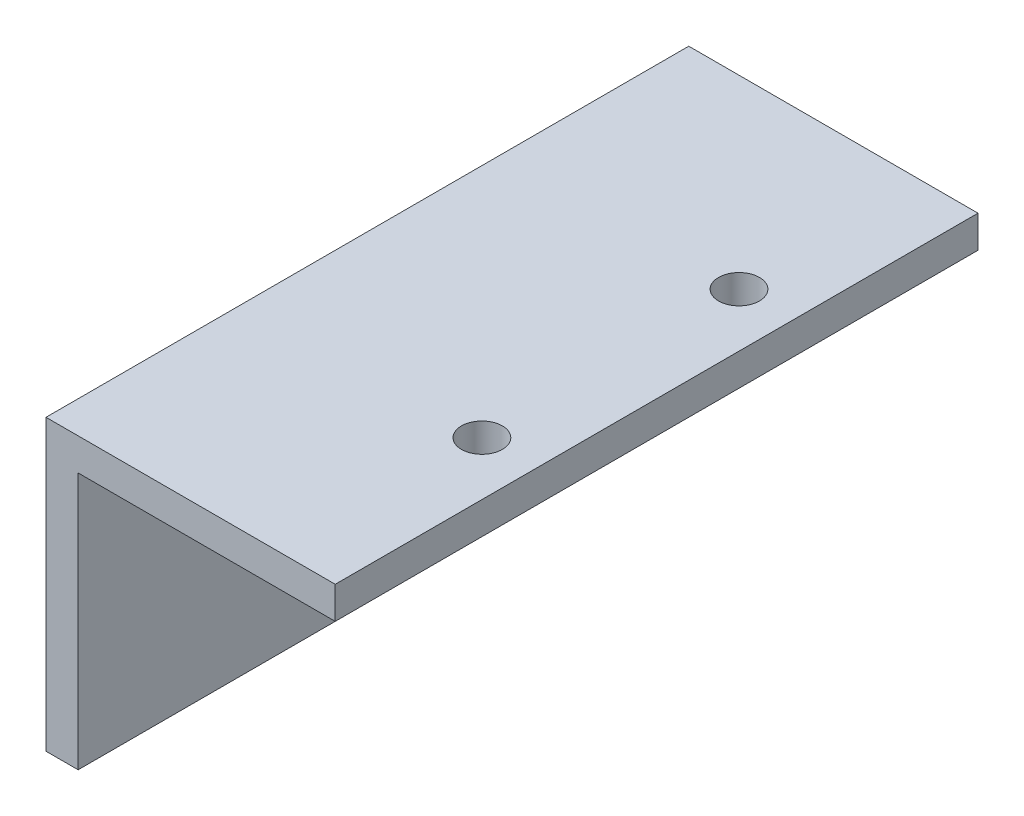
from build123d import *

# Parameters (mm, degrees)
BOSS_EXTRUDE1_DEPTH = 63.5
CUT_EXTRUDE1_REACH  = 30.575
SKETCH2_R           = 2.0193


with BuildPart() as part:
    # Sketch1 → Boss-Extrude1 (new body)
    with BuildSketch(Plane.XY):
        Polygon((0, 0), (0, 28.575), (28.575, 28.575), (28.575, 25.4), (3.175, 25.4), (3.175, 0), align=None)
    extrude(amount=BOSS_EXTRUDE1_DEPTH)

    # Sketch2 → Cut-Extrude1 (cut, up to next)
    with BuildSketch(Plane(origin=(0, 28.575, 0), x_dir=(1, 0, 0), z_dir=(0, 1, 0)), mode=Mode.PRIVATE) as cut_extrude1_sk1:
        with Locations((23.275, -43.710246093)):
            Circle(SKETCH2_R)
    cut_extrude1_tool1 = extrude(cut_extrude1_sk1.sketch, amount=-CUT_EXTRUDE1_REACH, mode=Mode.PRIVATE) & part.part
    add(cut_extrude1_tool1.solids().sort_by_distance((23.275, 28.575, 43.710246))[0], mode=Mode.SUBTRACT)
    # Sketch2 → Cut-Extrude1 (cut, up to next)
    with BuildSketch(Plane(origin=(0, 28.575, 0), x_dir=(1, 0, 0), z_dir=(0, 1, 0)), mode=Mode.PRIVATE) as cut_extrude1_sk2:
        with Locations((23.275, -18.310246093)):
            Circle(SKETCH2_R)
    cut_extrude1_tool2 = extrude(cut_extrude1_sk2.sketch, amount=-CUT_EXTRUDE1_REACH, mode=Mode.PRIVATE) & part.part
    add(cut_extrude1_tool2.solids().sort_by_distance((23.275, 28.575, 18.310246))[0], mode=Mode.SUBTRACT)


solid = part.part
